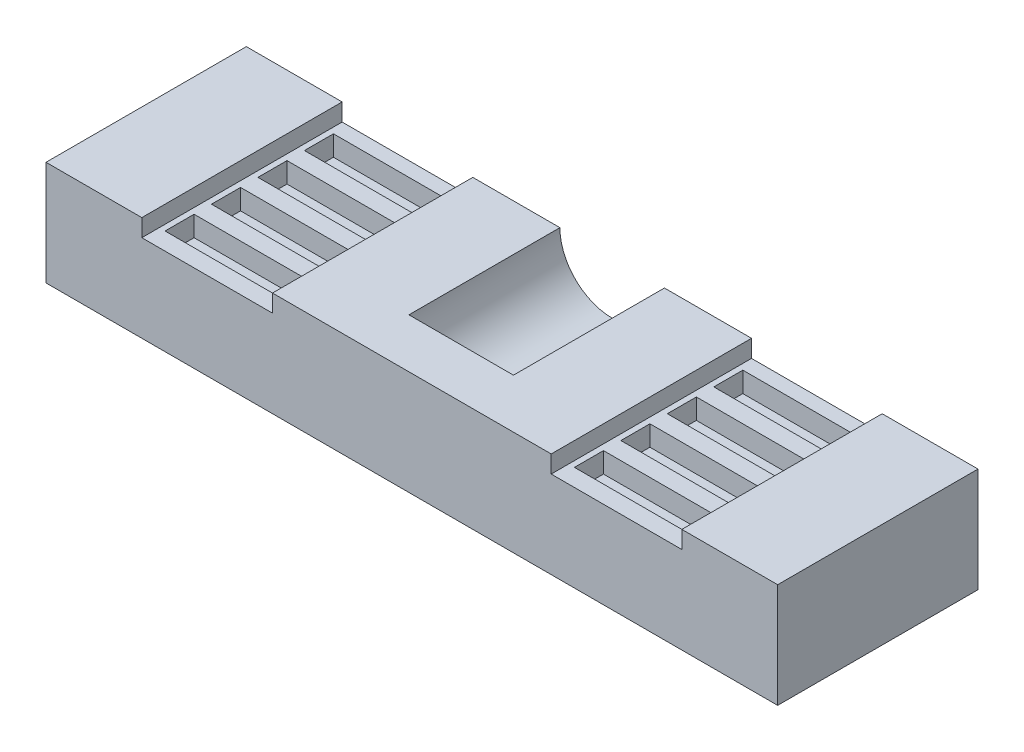
from build123d import *

# Parameters (mm, degrees)
SALIENTE_EXTRUIR1_DEPTH = 34.5
CROQUIS2_R              = 9
CORTAR_EXTRUIR1_DEPTH   = 26
CROQUIS3_W              = 10
CROQUIS3_H              = 5
CROQUIS3_W_2            = 10.5
CROQUIS3_W_3            = 20.5
CORTAR_EXTRUIR2_DEPTH   = 3.5


with BuildPart() as part:
    # Croquis1 → Saliente-Extruir1 (new body)
    with BuildSketch(Plane.XY):
        Polygon((0, 0), (0, 18), (16.5, 18), (16.5, 15), (39, 15), (39, 18), (87, 18), (87, 15), (109.5, 15), (109.5, 18), (126, 18), (126, 0), align=None)
    extrude(amount=SALIENTE_EXTRUIR1_DEPTH)

    # Croquis2 → Cortar-Extruir1 (cut)
    with BuildSketch(Plane(origin=(0, 0, 0), x_dir=(-1, 0, 0), z_dir=(0, 0, -1))):
        with Locations((-63, 18)):
            Circle(CROQUIS2_R)
    extrude(amount=-CORTAR_EXTRUIR1_DEPTH, mode=Mode.SUBTRACT)

    # Croquis3 → Cortar-Extruir2 (cut)
    with BuildSketch(Plane(origin=(0, 15, 0), x_dir=(1, 0, 0), z_dir=(0, 1, 0))):
        with Locations((22.5, -29)):
            Rectangle(CROQUIS3_W, CROQUIS3_H)
        with Locations((32.75, -29)):
            Rectangle(CROQUIS3_W_2, CROQUIS3_H)
        with Locations((32.75, -21)):
            Rectangle(CROQUIS3_W_2, CROQUIS3_H)
        with Locations((22.5, -21)):
            Rectangle(CROQUIS3_W, CROQUIS3_H)
        with Locations((32.75, -13)):
            Rectangle(CROQUIS3_W_2, CROQUIS3_H)
        with Locations((22.5, -13)):
            Rectangle(CROQUIS3_W, CROQUIS3_H)
        with Locations((32.75, -5)):
            Rectangle(CROQUIS3_W_2, CROQUIS3_H)
        with Locations((22.5, -5)):
            Rectangle(CROQUIS3_W, CROQUIS3_H)
        with Locations((98.25, -29)):
            Rectangle(CROQUIS3_W_3, CROQUIS3_H)
        with Locations((98.25, -21)):
            Rectangle(CROQUIS3_W_3, CROQUIS3_H)
        with Locations((98.25, -13)):
            Rectangle(CROQUIS3_W_3, CROQUIS3_H)
        with Locations((98.25, -5)):
            Rectangle(CROQUIS3_W_3, CROQUIS3_H)
    extrude(amount=-CORTAR_EXTRUIR2_DEPTH, mode=Mode.SUBTRACT)


solid = part.part
